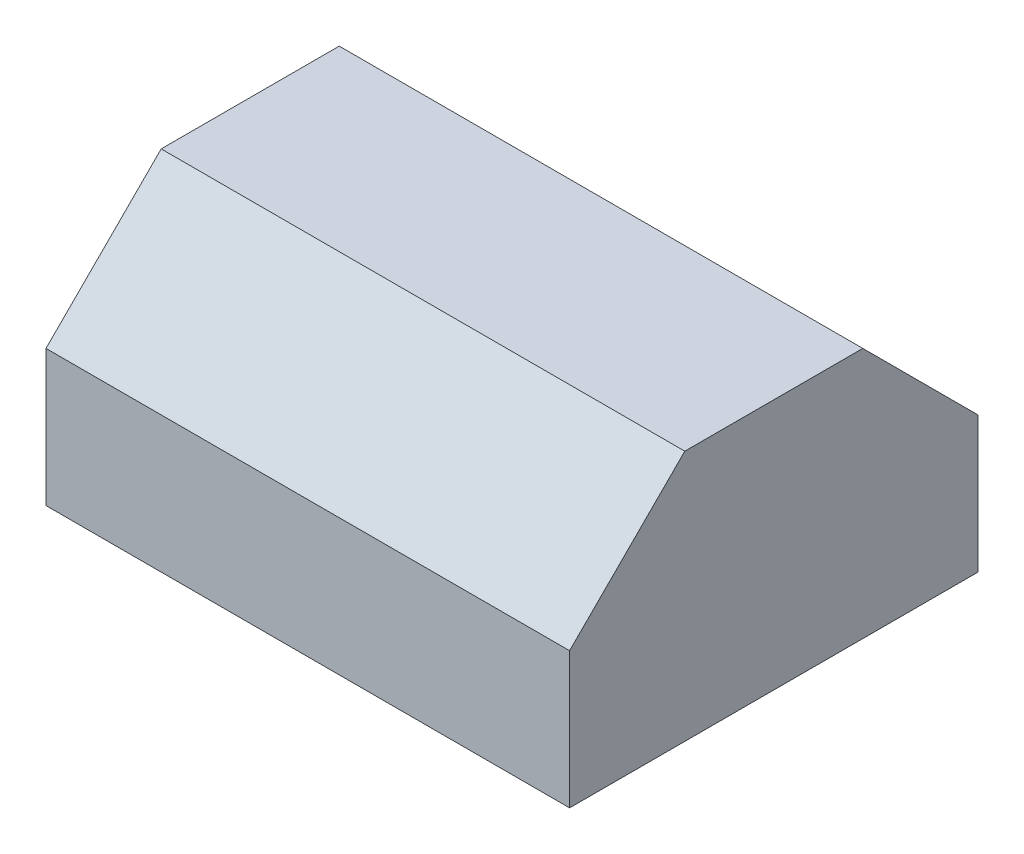
from build123d import *

# Parameters (mm, degrees)
BOSS_EXTRUDE1_DEPTH = 250
SHELL1_T            = -5
SKETCH4_W           = 10
SKETCH4_H           = 5
BOSS_EXTRUDE3_DEPTH = 5
SKETCH5_R           = 1.25
CUT_EXTRUDE3_DEPTH  = 241
FILLET2_R           = 2


with BuildPart() as part:
    # Sketch1 → Boss-Extrude1 (new body)
    with BuildSketch(Plane(origin=(0, 0, 0), x_dir=(0, 0, -1), z_dir=(1, 0, 0))):
        Polygon((0, 0), (195, 0), (195, 65), (140, 120), (55, 120), (0, 65), align=None)
    extrude(amount=BOSS_EXTRUDE1_DEPTH)

    # Shell1
    shell1_openings = [part.faces().sort_by_distance(p)[0] for p in [
        (125, 0, -97.5),
    ]]
    offset(amount=SHELL1_T, openings=shell1_openings, kind=Kind.INTERSECTION)

    # Sketch4 → Boss-Extrude3 (add)
    with BuildSketch(Plane.XZ):
        with Locations((15, -192.5)):
            Rectangle(SKETCH4_W, SKETCH4_H)
        with Locations((235, -192.5)):
            Rectangle(SKETCH4_W, SKETCH4_H)
    extrude(amount=BOSS_EXTRUDE3_DEPTH)

    # Sketch5 → Cut-Extrude3 (cut, through all)
    with BuildSketch(Plane(origin=(240, 0, 0), x_dir=(0, 0, -1), z_dir=(1, 0, 0))):
        with Locations((192.5, -2.5)):
            Circle(SKETCH5_R)
    extrude(amount=-CUT_EXTRUDE3_DEPTH, mode=Mode.SUBTRACT)

    # Fillet2
    fillet2_edges = [part.edges().sort_by_distance(p)[0] for p in [
        (235, -5, -195),
        (235, -5, -190),
        (15, -5, -190),
        (15, -5, -195),
    ]]
    fillet(fillet2_edges, radius=FILLET2_R)


solid = part.part
